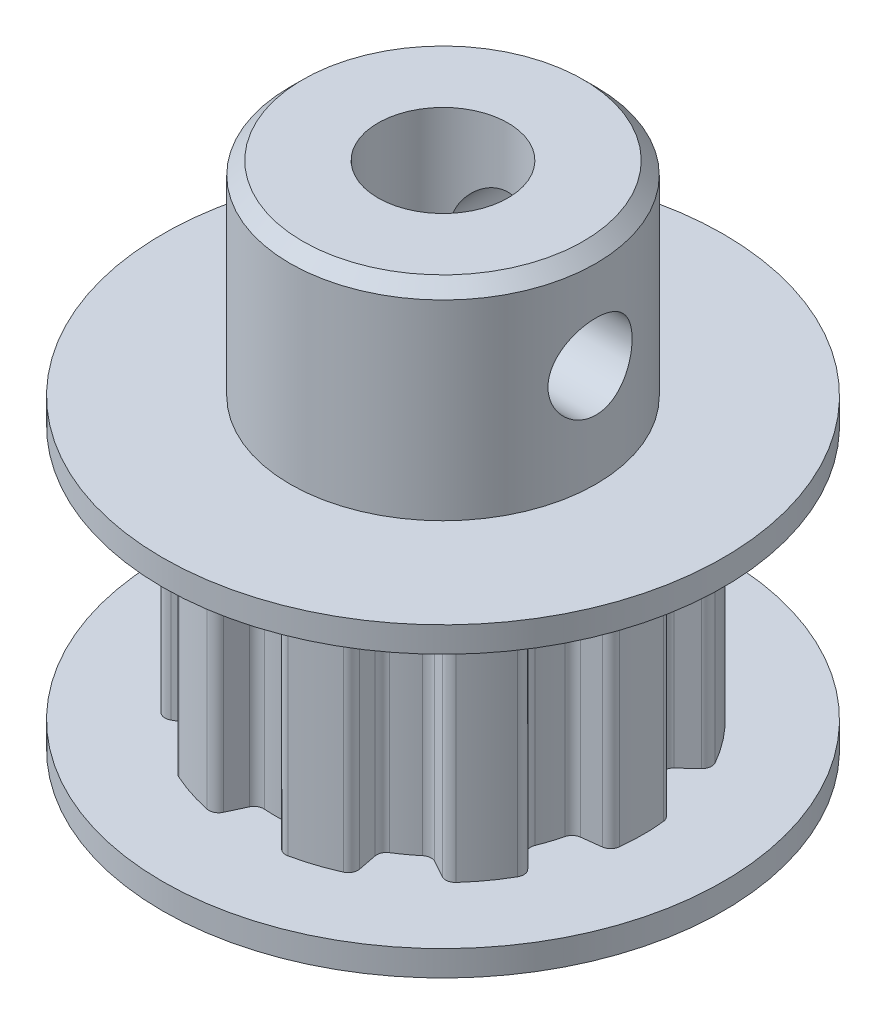
from build123d import *

# Parameters (mm, degrees)
SKETCH1_R                = 7.83
BOSS_EXTRUDE1_DEPTH      = 10
CUT_EXTRUDE1_DEPTH       = 14.660812567
FILLET1_R                = 0.38
CIRPATTERN1_COUNT        = 10
FILLET1_OF_CIRPATTERN1_R = 0.38
SKETCH3_R                = 2.55
CUT_EXTRUDE2_DEPTH       = 15.840354998
SKETCH4_R                = 11
BOSS_EXTRUDE2_DEPTH      = 1
SKETCH5_R                = 11
BOSS_EXTRUDE3_DEPTH      = 1
SKETCH6_R                = 6
BOSS_EXTRUDE4_DEPTH      = 8
SKETCH7_R                = 2.55
CUT_EXTRUDE3_DEPTH       = 26.337718919
CUT_EXTRUDE3_DEPTH_BACK  = 26.337718919
M4_TAPPED_HOLE1_REACH    = 27.807
M4_TAPPED_HOLE1_BORE_R   = 1.65
M4_TAPPED_HOLE2_REACH    = 27.807
M4_TAPPED_HOLE2_BORE_R   = 1.65
CHAMFER1_SIZE            = 0.5


with BuildPart() as part:
    # Sketch1 → Boss-Extrude1 (new body)
    with BuildSketch(Plane(origin=(0, 0, 0), x_dir=(1, 0, 0), z_dir=(0, 1, 0))):
        with Locations(Location((0, 0, 0), (0, 0, 270))):
            Circle(SKETCH1_R)
    extrude(amount=BOSS_EXTRUDE1_DEPTH)

    # Sketch2 → Cut-Extrude1 (cut, symmetric)
    with BuildSketch(Plane(origin=(0, 2, 0), x_dir=(1, 0, 0), z_dir=(0, 1, 0))):
        with BuildLine():
            Line((-1.285, 7.7238381), (-0.723625557, 6.519966722))
            ThreePointArc((-0.723625557, 6.519966722), (0, 6.56), (0.723625557, 6.519966722))
            Line((0.723625557, 6.519966722), (1.285, 7.7238381))
            ThreePointArc((1.285, 7.7238381), (0, 7.83), (-1.285, 7.7238381))
        make_face()
    cut_extrude1 = extrude(amount=CUT_EXTRUDE1_DEPTH, both=True, mode=Mode.SUBTRACT)

    # Fillet1
    fillet1_edges = [part.edges().sort_by_distance(p)[0] for p in [
        (1.285, 5, -7.7238381),
        (0.723625557, 5, -6.519966722),
        (-0.723625557, 5, -6.519966722),
        (-1.285, 5, -7.7238381),
    ]]
    fillet(fillet1_edges, radius=FILLET1_R)

    # CirPattern1: Cut-Extrude1 ×10 about axis
    cirpattern1_axis = Axis((0, 0, 0), (0, 1, 0))
    for i in range(1, CIRPATTERN1_COUNT):
        add(cut_extrude1.rotate(cirpattern1_axis, i * 360 / CIRPATTERN1_COUNT), mode=Mode.SUBTRACT)

    # Fillet1 of CirPattern1
    fillet1_of_cirpattern1_edges = [part.edges().sort_by_distance(p)[0] for p in [
        (-3.500371289, 5, -7.004020334),
        (-3.246914912, 5, -5.700100311),
        (-4.417765658, 5, -4.84942745),
        (-5.579544964, 5, -5.493412236),
        (-6.948719718, 5, -3.608904858),
        (-5.977244242, 5, -2.702989321),
        (-6.424469431, 5, -1.326571719),
        (-7.742893394, 5, -1.164689611),
        (-7.742893394, 5, 1.164689611),
        (-6.424469431, 5, 1.326571719),
        (-5.977244242, 5, 2.702989321),
        (-6.948719718, 5, 3.608904858),
        (-5.579544964, 5, 5.493412236),
        (-4.417765658, 5, 4.84942745),
        (-3.246914912, 5, 5.700100311),
        (-3.500371289, 5, 7.004020334),
        (-1.285, 5, 7.7238381),
        (-0.723625557, 5, 6.519966722),
        (0.723625557, 5, 6.519966722),
        (1.285, 5, 7.7238381),
        (3.500371289, 5, 7.004020334),
        (3.246914912, 5, 5.700100311),
        (4.417765658, 5, 4.84942745),
        (5.579544964, 5, 5.493412236),
        (6.948719718, 5, 3.608904858),
        (5.977244242, 5, 2.702989321),
        (6.424469431, 5, 1.326571719),
        (7.742893394, 5, 1.164689611),
        (7.742893394, 5, -1.164689611),
        (6.424469431, 5, -1.326571719),
        (5.977244242, 5, -2.702989321),
        (6.948719718, 5, -3.608904858),
        (5.579544964, 5, -5.493412236),
        (4.417765658, 5, -4.84942745),
        (3.246914912, 5, -5.700100311),
        (3.500371289, 5, -7.004020334),
    ]]
    fillet(fillet1_of_cirpattern1_edges, radius=FILLET1_OF_CIRPATTERN1_R)

    # Sketch3 → Cut-Extrude2 (cut, through all)
    with BuildSketch(Plane(origin=(0, 10, 0), x_dir=(1, 0, 0), z_dir=(0, 1, 0))):
        with Locations(Location((0, 0, 0), (0, 0, 270))):
            Circle(SKETCH3_R)
    extrude(amount=-CUT_EXTRUDE2_DEPTH, mode=Mode.SUBTRACT)

    # Sketch4 → Boss-Extrude2 (add)
    with BuildSketch(Plane.XZ):
        with Locations(Location((0, 0, 0), (0, 0, 270))):
            Circle(SKETCH4_R)
    extrude(amount=BOSS_EXTRUDE2_DEPTH)

    # Sketch5 → Boss-Extrude3 (add)
    with BuildSketch(Plane(origin=(0, 10, 0), x_dir=(1, 0, 0), z_dir=(0, 1, 0))):
        with Locations(Location((0, 0, 0), (0, 0, 90))):
            Circle(SKETCH5_R)
    extrude(amount=BOSS_EXTRUDE3_DEPTH)

    # Sketch6 → Boss-Extrude4 (add)
    with BuildSketch(Plane(origin=(0, 11, 0), x_dir=(1, 0, 0), z_dir=(0, 1, 0))):
        with Locations(Location((0, 0, 0), (0, 0, 270))):
            Circle(SKETCH6_R)
    extrude(amount=BOSS_EXTRUDE4_DEPTH)

    # Sketch7 → Cut-Extrude3 (cut, two sides)
    with BuildSketch(Plane(origin=(0, 19, 0), x_dir=(1, 0, 0), z_dir=(0, 1, 0))) as cut_extrude3_sk:
        with Locations(Location((0, 0, 0), (0, 0, 270))):
            Circle(SKETCH7_R)
    extrude(amount=CUT_EXTRUDE3_DEPTH, mode=Mode.SUBTRACT)
    extrude(cut_extrude3_sk.sketch, amount=-CUT_EXTRUDE3_DEPTH_BACK, mode=Mode.SUBTRACT)

    # M4 Tapped Hole1 bore (on position points) → M4 Tapped Hole1 (cut, up to next)
    with BuildSketch(Plane(origin=(0, 15, -6), x_dir=(-1, 0, 0), z_dir=(0, 0, -1)), mode=Mode.PRIVATE) as m4_tapped_hole1_sk1:
        Circle(M4_TAPPED_HOLE1_BORE_R)
    m4_tapped_hole1_tool1 = extrude(m4_tapped_hole1_sk1.sketch, amount=-M4_TAPPED_HOLE1_REACH, mode=Mode.PRIVATE) & part.part
    add(m4_tapped_hole1_tool1.solids().sort_by_distance((0, 15, -6))[0], mode=Mode.SUBTRACT)

    # M4 Tapped Hole2 bore (on position points) → M4 Tapped Hole2 (cut, up to next)
    with BuildSketch(Plane(origin=(6, 15, 0), x_dir=(0, 0, 1), z_dir=(1, 0, 0)), mode=Mode.PRIVATE) as m4_tapped_hole2_sk1:
        Circle(M4_TAPPED_HOLE2_BORE_R)
    m4_tapped_hole2_tool1 = extrude(m4_tapped_hole2_sk1.sketch, amount=-M4_TAPPED_HOLE2_REACH, mode=Mode.PRIVATE) & part.part
    add(m4_tapped_hole2_tool1.solids().sort_by_distance((6, 15, 0))[0], mode=Mode.SUBTRACT)

    # Chamfer1
    chamfer1_edges = [part.edges().sort_by_distance(p)[0] for p in [
        (0, 19, -6),
    ]]
    chamfer(chamfer1_edges, length=CHAMFER1_SIZE)


solid = part.part
